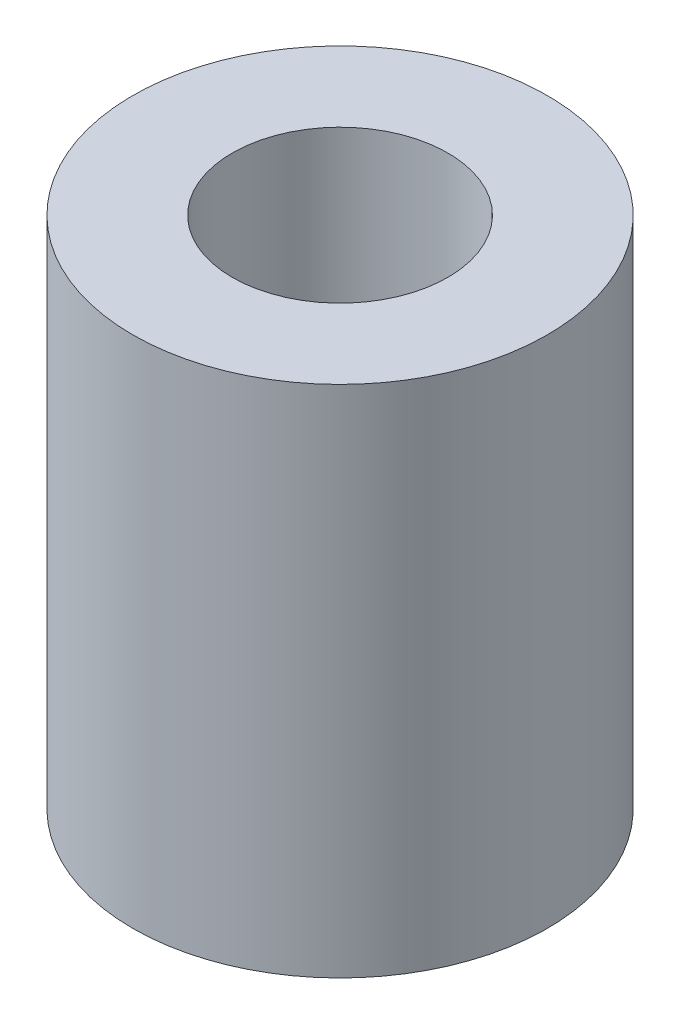
from build123d import *

# Parameters (mm, degrees)
ESQUISSE1_R      = 12.5
ESQUISSE1_R_2    = 6.5
EXTRUSION1_DEPTH = 31


with BuildPart() as part:
    # Esquisse1 → Extrusion1 (new body)
    with BuildSketch(Plane(origin=(0, 0, 0), x_dir=(1, 0, 0), z_dir=(0, 1, 0))):
        Circle(ESQUISSE1_R)
        Circle(ESQUISSE1_R_2, mode=Mode.SUBTRACT)
    extrude(amount=EXTRUSION1_DEPTH)


solid = part.part
